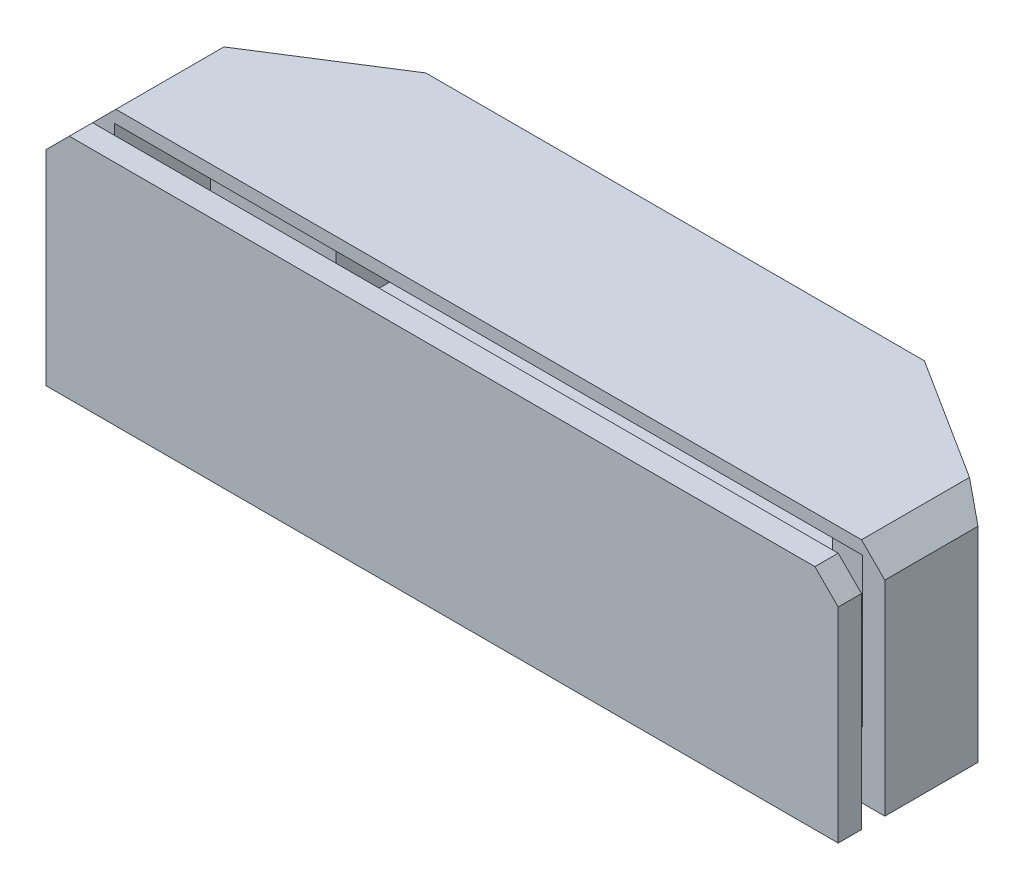
from build123d import *

# Parameters (mm, degrees)
BOSS_EXTRUDE1_DEPTH      = 7.5
BOSS_EXTRUDE1_DEPTH_BACK = 12.05
SKETCH1_W                = 42.6
SKETCH1_H                = 12.8
CUT_EXTRUDE1_DEPTH       = 7.2
SKETCH1_2_W              = 42.6
SKETCH1_2_H              = 12.8
CUT_EXTRUDE2_DEPTH       = 37.960677854
SKETCH3_W                = 64.2
SKETCH3_H                = 12.8
CUT_EXTRUDE3_DEPTH       = 8.2
BOSS_EXTRUDE2_START      = 2
SKETCH4_W                = 68
SKETCH4_H                = 19.55
BOSS_EXTRUDE2_DEPTH      = 2
CHAMFER1_SIZE            = 2
CHAMFER2_SIZE            = 2


with BuildPart() as part:
    # Sketch2 → Boss-Extrude1 (new, two sides: drawn at the far end of the back side and taken through both)
    with BuildSketch(Plane(origin=(0, 0, 0), x_dir=(1, 0, 0), z_dir=(0, 1, 0)).offset(-BOSS_EXTRUDE1_DEPTH_BACK)):
        Polygon((-34, 0.055383753), (-21.4, 8.055383753), (21.4, 8.055383753), (34, 0.055383753), (34, -7.944616247), (-34, -7.944616247), align=None)
    extrude(amount=BOSS_EXTRUDE1_DEPTH + BOSS_EXTRUDE1_DEPTH_BACK)

    # Sketch1 → Cut-Extrude1 (cut)
    with BuildSketch(Plane.XY):
        Rectangle(SKETCH1_W, SKETCH1_H)
    extrude(amount=-CUT_EXTRUDE1_DEPTH, mode=Mode.SUBTRACT)

    # Sketch1_2 → Cut-Extrude2 (cut, through all)
    with BuildSketch(Plane.XY):
        Rectangle(SKETCH1_2_W, SKETCH1_2_H)
    extrude(amount=CUT_EXTRUDE2_DEPTH, mode=Mode.SUBTRACT)

    # Sketch3 → Cut-Extrude3 (cut)
    with BuildSketch(Plane.XY.offset(7.944616247)):
        Rectangle(SKETCH3_W, SKETCH3_H)
    extrude(amount=-CUT_EXTRUDE3_DEPTH, mode=Mode.SUBTRACT)

    # Chamfer1
    chamfer1_edges = [part.edges().sort_by_distance(p)[0] for p in [
        (34, 7.5, 3.944616247),
        (-34, 7.5, 3.944616247),
    ]]
    chamfer(chamfer1_edges, length=CHAMFER1_SIZE)


with BuildPart() as body_2:
    # Sketch4 → Boss-Extrude2 (new body)
    with BuildSketch(Plane.XY.offset(7.944616247).offset(BOSS_EXTRUDE2_START)):
        with Locations((0, -2.275)):
            Rectangle(SKETCH4_W, SKETCH4_H)
    extrude(amount=BOSS_EXTRUDE2_DEPTH)

    # Chamfer2
    chamfer2_edges = [body_2.edges().sort_by_distance(p)[0] for p in [
        (34, 7.5, 10.944616247),
        (-34, 7.5, 10.944616247),
    ]]
    chamfer(chamfer2_edges, length=CHAMFER2_SIZE)


solid = Compound([part.part, body_2.part])
